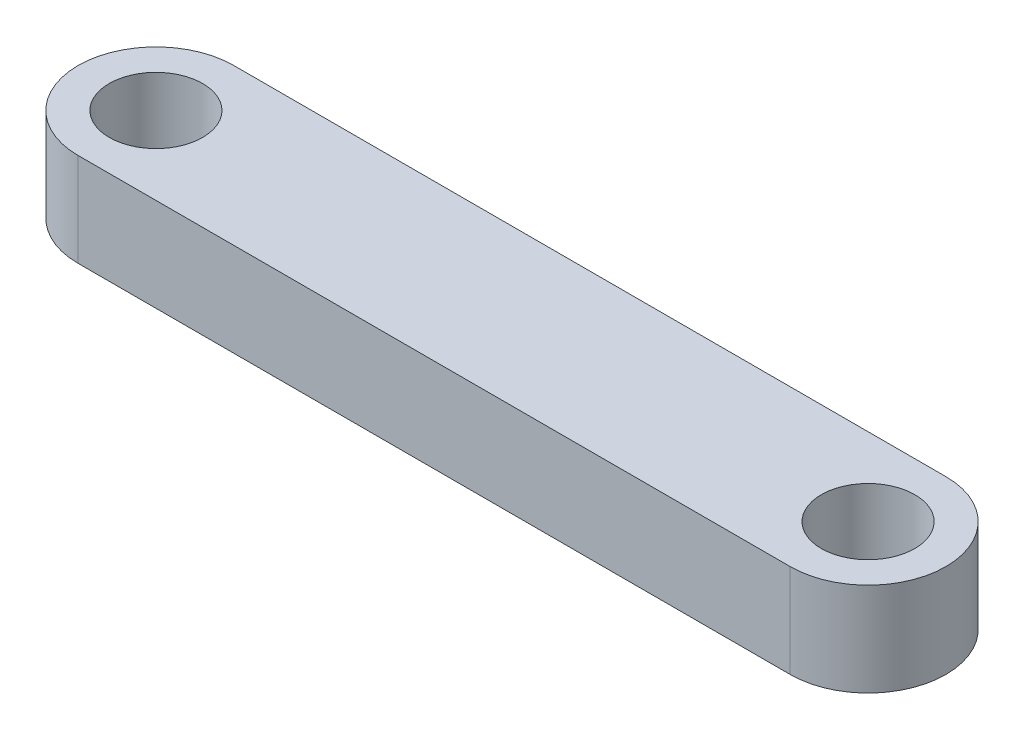
from build123d import *

# Parameters (mm, degrees)
SKETCH1_R           = 1.5
BOSS_EXTRUDE2_DEPTH = 1.5


with BuildPart() as part:
    # Sketch1 → Boss-Extrude2 (new body, symmetric)
    with BuildSketch(Plane(origin=(0, 0, 0), x_dir=(1, 0, 0), z_dir=(0, 1, 0))):
        with BuildLine():
            Line((-11.43, 2.5), (11.43, 2.5))
            ThreePointArc((11.43, 2.5), (13.93, 0), (11.43, -2.5))
            Line((11.43, -2.5), (-11.43, -2.5))
            ThreePointArc((-11.43, -2.5), (-13.93, 0), (-11.43, 2.5))
        make_face()
        with Locations((-11.43, 0)):
            Circle(SKETCH1_R, mode=Mode.SUBTRACT)
        with Locations((11.43, 0)):
            Circle(SKETCH1_R, mode=Mode.SUBTRACT)
    extrude(amount=BOSS_EXTRUDE2_DEPTH, both=True)


solid = part.part
